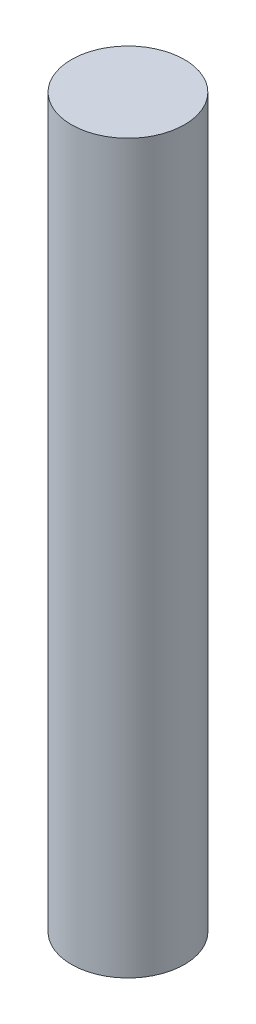
from build123d import *

# Parameters (mm, degrees)
SKETCH1_R           = 36.5125
BOSS_EXTRUDE1_DEPTH = 469.9


with BuildPart() as part:
    # Sketch1 → Boss-Extrude1 (new body)
    with BuildSketch(Plane(origin=(0, 0, 0), x_dir=(1, 0, 0), z_dir=(0, 1, 0))):
        Circle(SKETCH1_R)
    extrude(amount=BOSS_EXTRUDE1_DEPTH)


solid = part.part
